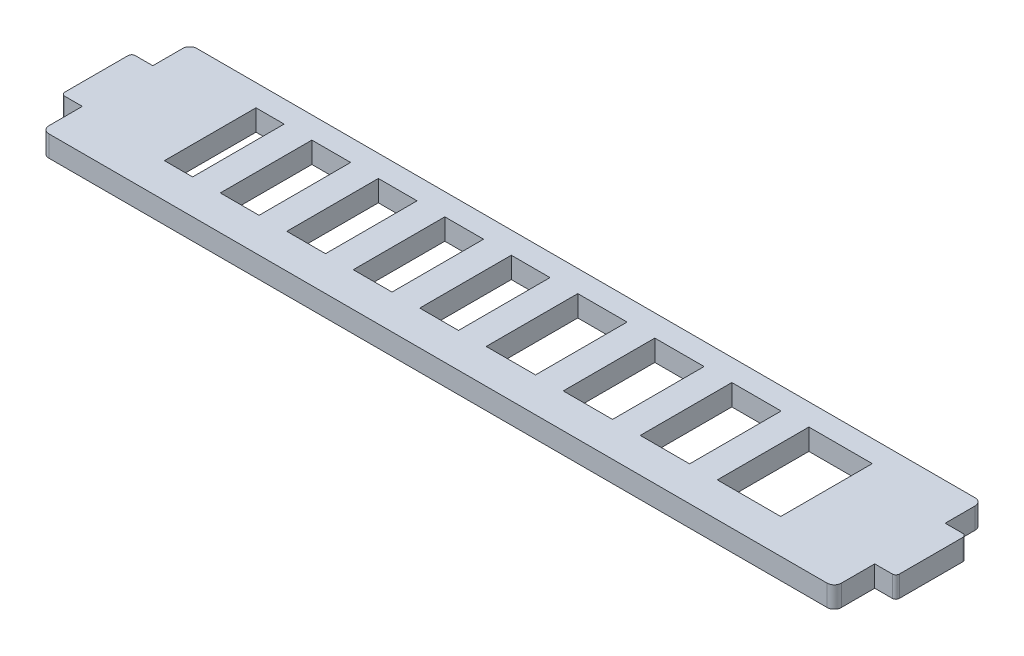
from build123d import *

# Parameters (mm, degrees)
SKETCH_1_W      = 4
SKETCH_1_H      = 13
SKETCH_1_W_2    = 9
SKETCH_1_W_3    = 5.5
SKETCH_1_W_4    = 7
EXTRUDE_1_DEPTH = 3
FILLET_1_R      = 0.5
FILLET_2_R      = 1


with BuildPart() as part:
    # Эскиз1 → Бобышка-Вытянуть1 (new body)
    with BuildSketch(Plane(origin=(0, 0, 0), x_dir=(1, 0, 0), z_dir=(0, 1, 0))):
        Polygon((-56.25, -11.4), (56.25, -11.4), (56.25, -5.65), (59.25, -5.65), (59.25, 4.35), (56.25, 4.35), (56.25, 9.6), (-56.25, 9.6), (-56.25, 4.35), (-59.25, 4.35), (-59.25, -5.65), (-56.25, -5.65), align=None)
        with Locations((-41.75, 0)):
            Rectangle(SKETCH_1_W, SKETCH_1_H, mode=Mode.SUBTRACT)
        with Locations((39.25, 0)):
            Rectangle(SKETCH_1_W_2, SKETCH_1_H, mode=Mode.SUBTRACT)
        with Locations((-23.625, 0)):
            Rectangle(SKETCH_1_W_3, SKETCH_1_H, mode=Mode.SUBTRACT)
        with Locations((-33.0625, 0)):
            Rectangle(SKETCH_1_W_3, SKETCH_1_H, mode=Mode.SUBTRACT)
        with Locations((-14.1875, 0)):
            Rectangle(SKETCH_1_W_3, SKETCH_1_H, mode=Mode.SUBTRACT)
        with Locations((-4.75, 0)):
            Rectangle(SKETCH_1_W_3, SKETCH_1_H, mode=Mode.SUBTRACT)
        with Locations((16.375, 0)):
            Rectangle(SKETCH_1_W_4, SKETCH_1_H, mode=Mode.SUBTRACT)
        with Locations((5.4375, 0)):
            Rectangle(SKETCH_1_W_4, SKETCH_1_H, mode=Mode.SUBTRACT)
        with Locations((27.3125, 0)):
            Rectangle(SKETCH_1_W_4, SKETCH_1_H, mode=Mode.SUBTRACT)
    extrude(amount=EXTRUDE_1_DEPTH)

    # Скругление1
    fillet_1_edges = [part.edges().sort_by_distance(p)[0] for p in [
        (-59.25, 1.5, 5.65),
        (-59.25, 1.5, -4.35),
        (59.25, 1.5, -4.35),
        (59.25, 1.5, 5.65),
    ]]
    fillet(fillet_1_edges, radius=FILLET_1_R)

    # Скругление2
    fillet_2_edges = [part.edges().sort_by_distance(p)[0] for p in [
        (-56.25, 1.5, -9.6),
        (56.25, 1.5, -9.6),
        (56.25, 1.5, 11.4),
        (-56.25, 1.5, 11.4),
    ]]
    fillet(fillet_2_edges, radius=FILLET_2_R)


solid = part.part
